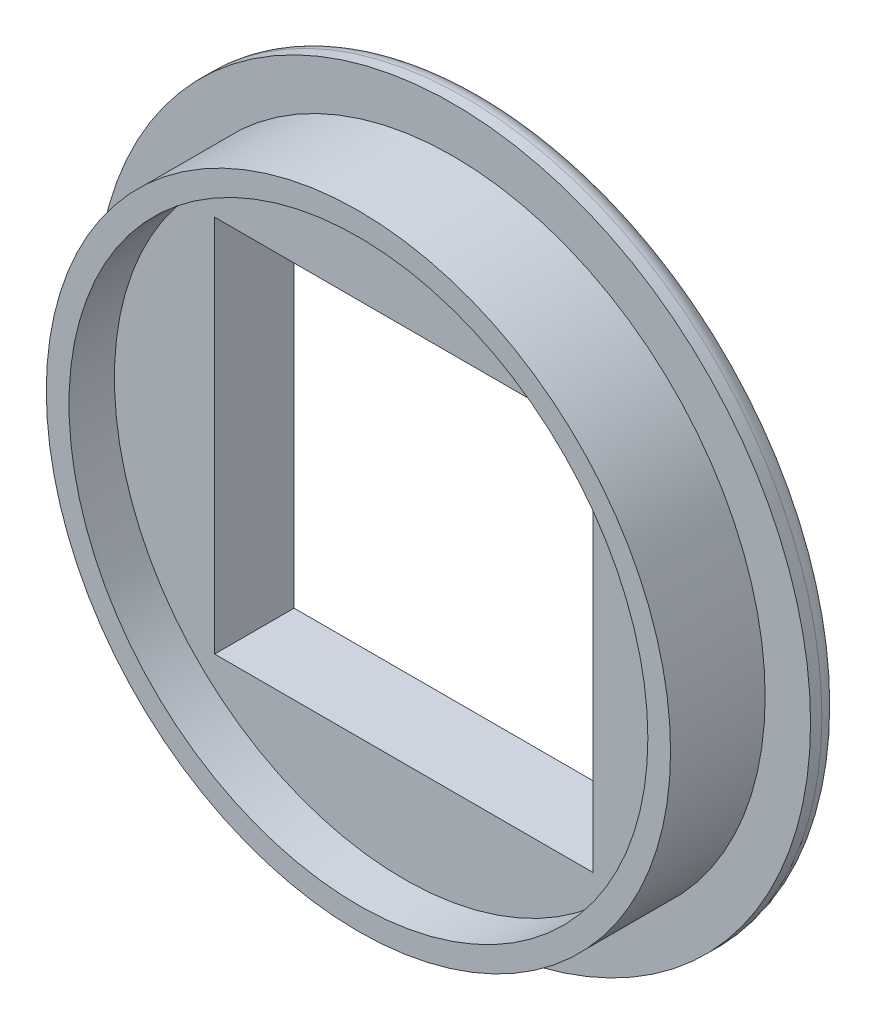
from build123d import *

# Parameters (mm, degrees)
SKETCH2_R           = 8.25
SKETCH2_W           = 10
SKETCH2_H           = 10
BOSS_EXTRUDE1_DEPTH = 3.3
SKETCH3_R           = 9.45
SKETCH3_W           = 10
SKETCH3_H           = 10
BOSS_EXTRUDE2_DEPTH = 0.8
SKETCH4_R           = 7.65
CUT_EXTRUDE1_DEPTH  = 1.2
FILLET1_R           = 0.5


with BuildPart() as part:
    # Sketch2 → Boss-Extrude1 (new body)
    with BuildSketch(Plane.XY):
        Circle(SKETCH2_R)
        Rectangle(SKETCH2_W, SKETCH2_H, mode=Mode.SUBTRACT)
    extrude(amount=BOSS_EXTRUDE1_DEPTH)

    # Sketch3 → Boss-Extrude2 (add)
    with BuildSketch(Plane(origin=(0, 0, 0), x_dir=(-1, 0, 0), z_dir=(0, 0, -1))):
        Circle(SKETCH3_R)
        Rectangle(SKETCH3_W, SKETCH3_H, mode=Mode.SUBTRACT)
    extrude(amount=-BOSS_EXTRUDE2_DEPTH)

    # Sketch4 → Cut-Extrude1 (cut)
    with BuildSketch(Plane.XY.offset(3.3)):
        Circle(SKETCH4_R)
    extrude(amount=-CUT_EXTRUDE1_DEPTH, mode=Mode.SUBTRACT)

    # Fillet1
    fillet1_edges = [part.edges().sort_by_distance(p)[0] for p in [
        (9.45, 0, 0),
    ]]
    fillet(fillet1_edges, radius=FILLET1_R)


solid = part.part
